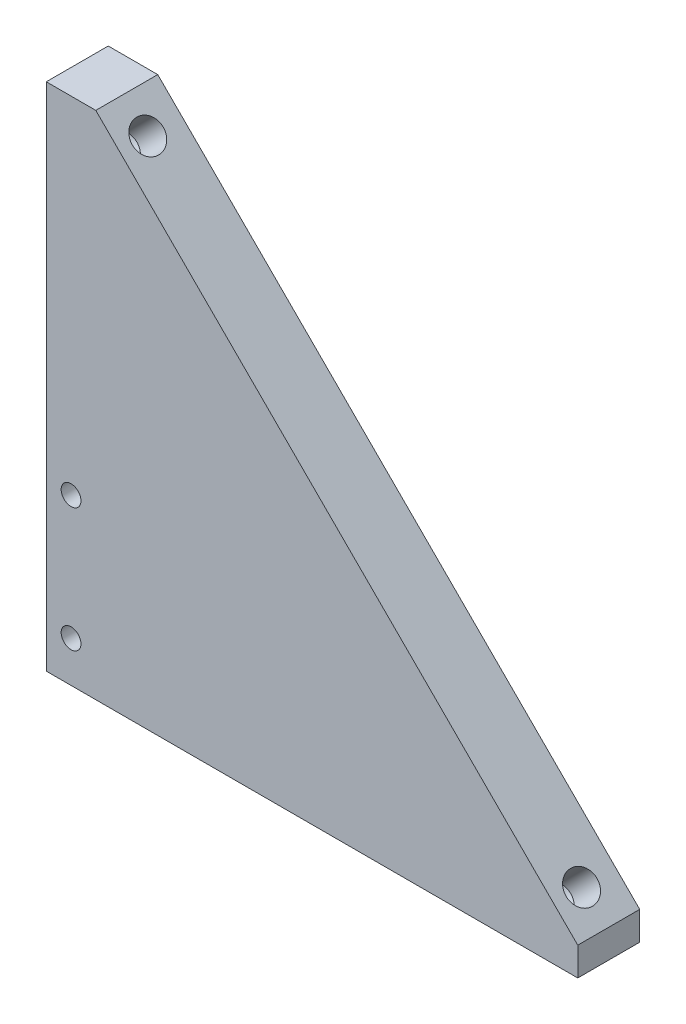
from build123d import *

# Parameters (mm, degrees)
BOSS_EXTRUDE1_DEPTH       = 5
M3X0_5_TAPPED_HOLE1_D     = 2.5
M3X0_5_TAPPED_HOLE1_DEPTH = 3
M3X0_5_TAPPED_HOLE1_TIP   = 0.751075774
BOSS_EXTRUDE2_DEPTH       = 5
CUT_EXTRUDE1_DEPTH        = 6
BOSS_EXTRUDE3_DEPTH       = 5
SKETCH12_W                = 42.426406872
SKETCH12_H                = 0.46
BOSS_EXTRUDE4_DEPTH       = 5
SKETCH13_W                = 0.46
SKETCH13_H                = 42.886406871
BOSS_EXTRUDE5_DEPTH       = 5
M2X0_4_TAPPED_HOLE1_D     = 1.6
SKETCH20_W                = 42.886406872
SKETCH20_H                = 1.7
CUT_EXTRUDE2_DEPTH        = 6
M3X0_5_TAPPED_HOLE3_D     = 2.5
M3X0_5_TAPPED_HOLE3_DEPTH = 6
M3X0_5_TAPPED_HOLE3_TIP   = 0.751075774


with BuildPart() as part:
    # Sketch2 → Boss-Extrude1 (new body)
    with BuildSketch(Plane.XY):
        Polygon((-19.445436483, 19.445436483), (26.516504294, -26.516504294), (-19.445436483, -26.516504294), align=None)
    extrude(amount=BOSS_EXTRUDE1_DEPTH)

    # M3x0.5 Tapped Hole1
    with Locations(Plane(origin=(0, 0, 0), x_dir=(0, 0, -1), z_dir=(0.707106781, 0.707106781, 0))):
        with Locations((-2.75, 19.75), (-2.75, -29.75)):
            Hole(M3X0_5_TAPPED_HOLE1_D / 2, depth=M3X0_5_TAPPED_HOLE1_DEPTH)
            with Locations((0, 0, -(M3X0_5_TAPPED_HOLE1_DEPTH + M3X0_5_TAPPED_HOLE1_TIP / 2))):  # 118° drill point
                Cone(0, M3X0_5_TAPPED_HOLE1_D / 2, M3X0_5_TAPPED_HOLE1_TIP, mode=Mode.SUBTRACT)

    # Sketch6 → Boss-Extrude2 (add, through all)
    with BuildSketch(Plane.XY.offset(5)):
        Polygon((-19.445436483, 19.445436483), (-15.909902577, 15.909902577), (-14.495689014, 17.324116139), (-18.03122292, 20.859650045), align=None)
        Polygon((26.516504294, -26.516504294), (22.980970389, -22.980970389), (24.395183951, -21.566756826), (27.930717857, -25.102290732), align=None)
    extrude(amount=-BOSS_EXTRUDE2_DEPTH)

    # Sketch7 → Cut-Extrude1 (cut, through all)
    with BuildSketch(Plane.XY.offset(5)):
        Polygon((-18.03122292, 20.859650045), (-14.495689014, 17.324116139), (-19.445436483, 12.374368671), (-19.445436483, 19.445436483), align=None)
        Polygon((24.395183951, -21.566756826), (19.445436483, -26.516504294), (26.516504294, -26.516504294), (27.930717857, -25.102290732), align=None)
    extrude(amount=-CUT_EXTRUDE1_DEPTH, mode=Mode.SUBTRACT)

    # Sketch11 → Boss-Extrude3 (add, through all)
    with BuildSketch(Plane(origin=(0, 0, 0), x_dir=(-1, 0, 0), z_dir=(0, 0, -1))):
        Polygon((-19.445436483, -26.516504294), (-22.980970389, -26.516504294), (-22.980970389, -22.980970389), align=None)
        Polygon((19.445436483, 12.374368671), (19.445436483, 15.909902577), (15.909902577, 15.909902577), align=None)
    extrude(amount=-BOSS_EXTRUDE3_DEPTH)

    # Sketch12 → Boss-Extrude4 (add, through all)
    with BuildSketch(Plane.XY.offset(5)):
        with Locations((1.767766953, -26.746504294)):
            Rectangle(SKETCH12_W, SKETCH12_H)
    extrude(amount=-BOSS_EXTRUDE4_DEPTH)

    # Sketch13 → Boss-Extrude5 (add, through all)
    with BuildSketch(Plane.XY.offset(5)):
        with Locations((-19.675436483, -5.533300859)):
            Rectangle(SKETCH13_W, SKETCH13_H)
    extrude(amount=-BOSS_EXTRUDE5_DEPTH)

    # M2x0.4 Tapped Hole1 (through all)
    with Locations(Plane(origin=(0, 0, 0), x_dir=(-1, 0, 0), z_dir=(0, 0, -1))):
        with Locations((17.905436483, -11.976504294), (17.905436483, -21.976504294)):
            Hole(M2X0_4_TAPPED_HOLE1_D / 2)

    # Sketch20 → Cut-Extrude2 (cut, through all)
    with BuildSketch(Plane.XY.offset(5)):
        with Locations((1.537766953, -26.126504294)):
            Rectangle(SKETCH20_W, SKETCH20_H)
    extrude(amount=-CUT_EXTRUDE2_DEPTH, mode=Mode.SUBTRACT)

    # M3x0.5 Tapped Hole3
    with Locations(Plane(origin=(0, -25.276504294, 0), x_dir=(-1, 0, 0), z_dir=(0, -1, 0))):
        with Locations((7.905436483, -2.5), (-7.094563517, -2.5)):
            Hole(M3X0_5_TAPPED_HOLE3_D / 2, depth=M3X0_5_TAPPED_HOLE3_DEPTH)
            with Locations((0, 0, -(M3X0_5_TAPPED_HOLE3_DEPTH + M3X0_5_TAPPED_HOLE3_TIP / 2))):  # 118° drill point
                Cone(0, M3X0_5_TAPPED_HOLE3_D / 2, M3X0_5_TAPPED_HOLE3_TIP, mode=Mode.SUBTRACT)


solid = part.part
